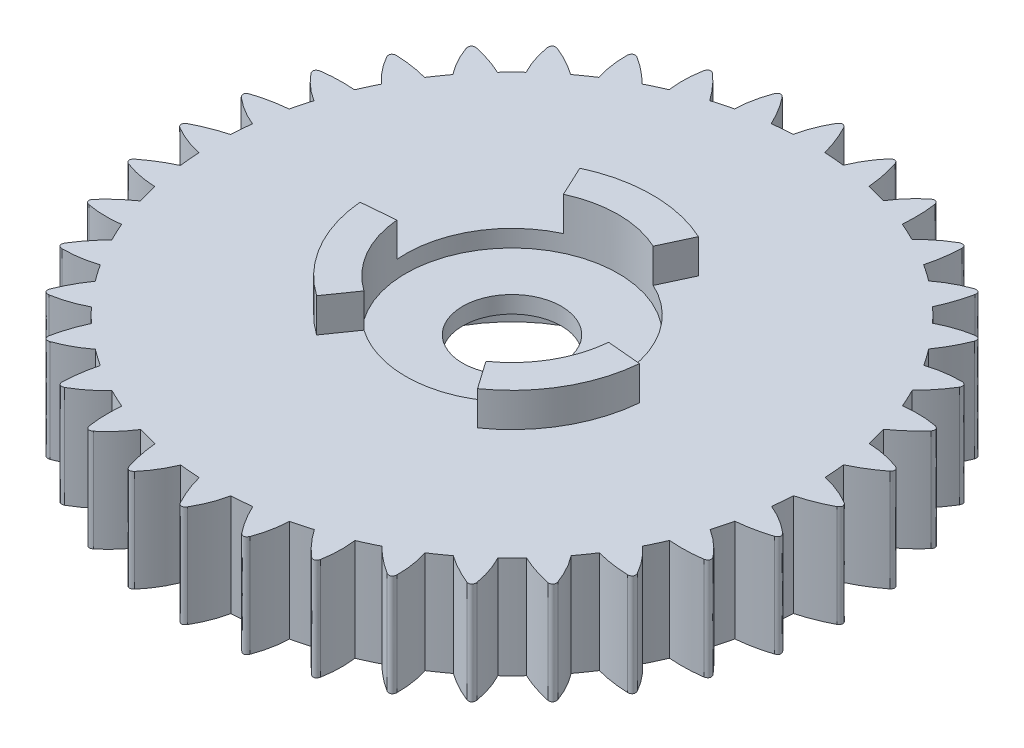
from build123d import *

# Parameters (mm, degrees)
SKETCH_1_R          = 17.5
EXTRUDE_1_DEPTH     = 6
SKETCH_2_R          = 8
CUT_EXTRUDE_1_DEPTH = 4
SKETCH_3_R          = 6.25
CUT_EXTRUDE_2_DEPTH = 1
SKETCH_4_R          = 2.9
CUT_EXTRUDE_3_DEPTH = 10
EXTRUDE_2_DEPTH     = 2
EXTRUDE_3_DEPTH     = 6


with BuildPart() as part:
    # 草图1 → 凸台-拉伸1 (new body)
    with BuildSketch(Plane(origin=(0, 0, 0), x_dir=(1, 0, 0), z_dir=(0, 1, 0))):
        Circle(SKETCH_1_R)
    extrude(amount=EXTRUDE_1_DEPTH)

    # 草图2 → 切除-拉伸1 (cut)
    with BuildSketch(Plane.XZ):
        Circle(SKETCH_2_R)
    extrude(amount=-CUT_EXTRUDE_1_DEPTH, mode=Mode.SUBTRACT)

    # 草图3 → 切除-拉伸2 (cut)
    with BuildSketch(Plane(origin=(0, 6, 0), x_dir=(1, 0, 0), z_dir=(0, 1, 0))):
        Circle(SKETCH_3_R)
    extrude(amount=-CUT_EXTRUDE_2_DEPTH, mode=Mode.SUBTRACT)

    # 草图4 → 切除-拉伸3 (cut)
    with BuildSketch(Plane.XZ.offset(-4)):
        Circle(SKETCH_4_R)
    extrude(amount=-CUT_EXTRUDE_3_DEPTH, mode=Mode.SUBTRACT)

    # 草图5 → 凸台-拉伸2 (add)
    with BuildSketch(Plane(origin=(0, 6, 0), x_dir=(1, 0, 0), z_dir=(0, 1, 0))):
        with BuildLine():
            Line((2.641364136, 5.664423669), (3.486600659, 7.477039243))
            ThreePointArc((3.486600659, 7.477039243), (0, 8.25), (-3.486600659, 7.477039243))
            Line((-3.486600659, 7.477039243), (-2.641364136, 5.664423669))
            ThreePointArc((-2.641364136, 5.664423669), (0, 6.25), (2.641364136, 5.664423669))
        make_face()
        with BuildLine():
            Line((3.584852727, -5.119700277), (4.7320056, -6.758004365))
            ThreePointArc((4.7320056, -6.758004365), (7.144709581, -4.125), (8.218606259, -0.719034878))
            Line((8.218606259, -0.719034878), (6.226216863, -0.544723392))
            ThreePointArc((6.226216863, -0.544723392), (5.412658774, -3.125), (3.584852727, -5.119700277))
        make_face()
        with BuildLine():
            Line((-6.226216863, -0.544723392), (-8.218606259, -0.719034878))
            ThreePointArc((-8.218606259, -0.719034878), (-7.144709581, -4.125), (-4.7320056, -6.758004365))
            Line((-4.7320056, -6.758004365), (-3.584852727, -5.119700277))
            ThreePointArc((-3.584852727, -5.119700277), (-5.412658774, -3.125), (-6.226216863, -0.544723392))
        make_face()
    extrude(amount=EXTRUDE_2_DEPTH)

    # 草图6 → 凸台-拉伸3 (add)
    with BuildSketch(Plane(origin=(0, 6, 0), x_dir=(1, 0, 0), z_dir=(0, 1, 0))):
        with BuildLine():
            Line((1.995624094, 17.076517128), (3.9652396, 16.729220773))
            add(Edge.make_bspline(
                [(3.546420744, 18.989060274), (3.785233358, 18.256333159), (3.924839643, 17.503053326), (3.9652396, 16.729220773)],
                knots=[0.14661217, 0.14661217, 0.14661217, 0.14661217, 1, 1, 1, 1], degree=3))
            add(Edge.make_bspline(
                [(3.137147772, 19.059965649), (3.395615745, 19.28991485), (3.546420744, 18.989060274)],
                knots=[0, 0, 0, 1, 1, 1], degree=2))
            add(Edge.make_bspline(
                [(3.137147772, 19.059965649), (2.636252172, 18.472842882), (2.255750312, 17.811700446), (1.995624094, 17.076517128)],
                knots=[0.150431817, 0.150431817, 0.150431817, 0.150431817, 1, 1, 1, 1], degree=3))
        make_face()
        with BuildLine():
            Line((-1, 17.163622949), (1, 17.163622949))
            add(Edge.make_bspline(
                [(0.195126932, 19.316403279), (0.557548174, 18.636277311), (0.825839196, 17.918683868), (1, 17.163622949)],
                knots=[0.14661217, 0.14661217, 0.14661217, 0.14661217, 1, 1, 1, 1], degree=3))
            add(Edge.make_bspline(
                [(-0.220240853, 19.315161937), (-0.005629849, 19.586500185), (0.195126932, 19.316403279)],
                knots=[0, 0, 0, 1, 1, 1], degree=2))
            add(Edge.make_bspline(
                [(-0.220240853, 19.315161937), (-0.611573925, 18.649979276), (-0.871488927, 17.932807625), (-1, 17.163622949)],
                knots=[0.150431817, 0.150431817, 0.150431817, 0.150431817, 1, 1, 1, 1], degree=3))
        make_face()
        with BuildLine():
            Line((4.93061216, 16.470549975), (6.809997402, 15.786509688))
            add(Edge.make_bspline(
                [(6.789958356, 18.08474428), (6.897906142, 17.321679562), (6.904585824, 16.555601365), (6.809997402, 15.786509688)],
                knots=[0.14661217, 0.14661217, 0.14661217, 0.14661217, 1, 1, 1, 1], degree=3))
            add(Edge.make_bspline(
                [(6.39921575, 18.225641949), (6.693687273, 18.407215213), (6.789958356, 18.08474428)],
                knots=[0, 0, 0, 1, 1, 1], degree=2))
            add(Edge.make_bspline(
                [(6.39921575, 18.225641949), (5.803977081, 17.734418505), (5.31444972, 17.149393763), (4.93061216, 16.470549975)],
                knots=[0.150431817, 0.150431817, 0.150431817, 0.150431817, 1, 1, 1, 1], degree=3))
        make_face()
        with BuildLine():
            Line((7.715786071, 15.364133495), (9.447836878, 14.364133495))
            add(Edge.make_bspline(
                [(9.82718652, 16.630932484), (9.800989538, 15.860715497), (9.674539658, 15.105115834), (9.447836878, 14.364133495)],
                knots=[0.14661217, 0.14661217, 0.14661217, 0.14661217, 1, 1, 1, 1], degree=3))
            add(Edge.make_bspline(
                [(9.466846795, 16.837541342), (9.7883745, 16.965221656), (9.82718652, 16.630932484)],
                knots=[0, 0, 0, 1, 1, 1], degree=2))
            add(Edge.make_bspline(
                [(9.466846795, 16.837541342), (8.795351083, 16.457142796), (8.211672262, 15.966011428), (7.715786071, 15.364133495)],
                knots=[0.150431817, 0.150431817, 0.150431817, 0.150431817, 1, 1, 1, 1], degree=3))
        make_face()
        with BuildLine():
            Line((10.266519726, 13.790885594), (11.798608612, 12.505310374))
            add(Edge.make_bspline(
                [(12.565820593, 14.671798219), (12.406274827, 13.917831617), (12.1505375, 13.195669002), (11.798608612, 12.505310374)],
                knots=[0.14661217, 0.14661217, 0.14661217, 0.14661217, 1, 1, 1, 1], degree=3))
            add(Edge.make_bspline(
                [(12.24683249, 14.937840561), (12.585646922, 15.007748424), (12.565820593, 14.671798219)],
                knots=[0, 0, 0, 1, 1, 1], degree=2))
            add(Edge.make_bspline(
                [(12.24683249, 14.937840561), (11.519482793, 14.67982513), (10.859387298, 14.297509915), (10.266519726, 13.790885594)],
                knots=[0.150431817, 0.150431817, 0.150431817, 0.150431817, 1, 1, 1, 1], degree=3))
        make_face()
        with BuildLine():
            Line((12.505310374, 11.798608612), (13.790885594, 10.266519726))
            add(Edge.make_bspline(
                [(14.922648567, 12.26686879), (14.634601733, 11.552061466), (14.257347408, 10.885278445), (13.790885594, 10.266519726)],
                knots=[0.14661217, 0.14661217, 0.14661217, 0.14661217, 1, 1, 1, 1], degree=3))
            add(Edge.make_bspline(
                [(14.654704378, 12.584261054), (15.00051083, 12.59427235), (14.922648567, 12.26686879)],
                knots=[0, 0, 0, 1, 1, 1], degree=2))
            add(Edge.make_bspline(
                [(14.654704378, 12.584261054), (13.893600847, 12.456468406), (13.177145346, 12.194585798), (12.505310374, 11.798608612)],
                knots=[0.150431817, 0.150431817, 0.150431817, 0.150431817, 1, 1, 1, 1], degree=3))
        make_face()
        with BuildLine():
            Line((14.364133495, 9.447836878), (15.364133495, 7.715786071))
            add(Edge.make_bspline(
                [(16.826059415, 9.48921676), (16.418263671, 8.835287773), (15.93095503, 8.24414421), (15.364133495, 7.715786071)],
                knots=[0.14661217, 0.14661217, 0.14661217, 0.14661217, 1, 1, 1, 1], degree=3))
            add(Edge.make_bspline(
                [(16.617300489, 9.848315142), (16.959591807, 9.798125685), (16.826059415, 9.48921676)],
                knots=[0, 0, 0, 1, 1, 1], degree=2))
            add(Edge.make_bspline(
                [(16.617300489, 9.848315142), (15.845568871, 9.854628193), (15.094522501, 9.721135363), (14.364133495, 9.447836878)],
                knots=[0.150431817, 0.150431817, 0.150431817, 0.150431817, 1, 1, 1, 1], degree=3))
        make_face()
        with BuildLine():
            Line((15.786509688, 6.809997402), (16.470549975, 4.93061216))
            add(Edge.make_bspline(
                [(18.218218963, 6.42323968), (17.703064975, 5.850058333), (17.120508645, 5.352515826), (16.470549975, 4.93061216)],
                knots=[0.14661217, 0.14661217, 0.14661217, 0.14661217, 1, 1, 1, 1], degree=3))
            add(Edge.make_bspline(
                [(18.074988333, 6.813133158), (18.403364169, 6.704267928), (18.218218963, 6.42323968)],
                knots=[0, 0, 0, 1, 1, 1], degree=2))
            add(Edge.make_bspline(
                [(18.074988333, 6.813133158), (17.316077302, 6.953360089), (16.553260227, 6.952313148), (15.786509688, 6.809997402)],
                knots=[0.150431817, 0.150431817, 0.150431817, 0.150431817, 1, 1, 1, 1], degree=3))
        make_face()
        with BuildLine():
            Line((16.729220773, 3.9652396), (17.076517128, 1.995624094))
            add(Edge.make_bspline(
                [(19.056827146, 3.162095713), (18.449967608, 2.687077829), (17.789864269, 2.298253956), (17.076517128, 1.995624094)],
                knots=[0.14661217, 0.14661217, 0.14661217, 0.14661217, 1, 1, 1, 1], degree=3))
            add(Edge.make_bspline(
                [(18.983476803, 3.570937571), (19.287959624, 3.406704383), (19.056827146, 3.162095713)],
                knots=[0, 0, 0, 1, 1, 1], degree=2))
            add(Edge.make_bspline(
                [(18.983476803, 3.570937571), (18.260445487, 3.840817658), (17.509035518, 3.972248417), (16.729220773, 3.9652396)],
                knots=[0.150431817, 0.150431817, 0.150431817, 0.150431817, 1, 1, 1, 1], degree=3))
        make_face()
        with BuildLine():
            Line((17.163622949, 1), (17.163622949, -1))
            add(Edge.make_bspline(
                [(19.316403279, -0.195126932), (18.636277311, -0.557548174), (17.918683868, -0.825839196), (17.163622949, -1)],
                knots=[0.14661217, 0.14661217, 0.14661217, 0.14661217, 1, 1, 1, 1], degree=3))
            add(Edge.make_bspline(
                [(19.315161937, 0.220240853), (19.586500185, 0.005629849), (19.316403279, -0.195126932)],
                knots=[0, 0, 0, 1, 1, 1], degree=2))
            add(Edge.make_bspline(
                [(19.315161937, 0.220240853), (18.649979276, 0.611573925), (17.932807625, 0.871488927), (17.163622949, 1)],
                knots=[0.150431817, 0.150431817, 0.150431817, 0.150431817, 1, 1, 1, 1], degree=3))
        make_face()
        with BuildLine():
            Line((17.076517128, -1.995624094), (16.729220773, -3.9652396))
            add(Edge.make_bspline(
                [(18.989060274, -3.546420744), (18.256333159, -3.785233358), (17.503053326, -3.924839643), (16.729220773, -3.9652396)],
                knots=[0.14661217, 0.14661217, 0.14661217, 0.14661217, 1, 1, 1, 1], degree=3))
            add(Edge.make_bspline(
                [(19.059965649, -3.137147772), (19.28991485, -3.395615745), (18.989060274, -3.546420744)],
                knots=[0, 0, 0, 1, 1, 1], degree=2))
            add(Edge.make_bspline(
                [(19.059965649, -3.137147772), (18.472842882, -2.636252172), (17.811700446, -2.255750312), (17.076517128, -1.995624094)],
                knots=[0.150431817, 0.150431817, 0.150431817, 0.150431817, 1, 1, 1, 1], degree=3))
        make_face()
        with BuildLine():
            Line((16.470549975, -4.93061216), (15.786509688, -6.809997402))
            add(Edge.make_bspline(
                [(18.08474428, -6.789958356), (17.321679562, -6.897906142), (16.555601365, -6.904585824), (15.786509688, -6.809997402)],
                knots=[0.14661217, 0.14661217, 0.14661217, 0.14661217, 1, 1, 1, 1], degree=3))
            add(Edge.make_bspline(
                [(18.225641949, -6.39921575), (18.407215213, -6.693687273), (18.08474428, -6.789958356)],
                knots=[0, 0, 0, 1, 1, 1], degree=2))
            add(Edge.make_bspline(
                [(18.225641949, -6.39921575), (17.734418505, -5.803977081), (17.149393763, -5.31444972), (16.470549975, -4.93061216)],
                knots=[0.150431817, 0.150431817, 0.150431817, 0.150431817, 1, 1, 1, 1], degree=3))
        make_face()
        with BuildLine():
            Line((15.364133495, -7.715786071), (14.364133495, -9.447836878))
            add(Edge.make_bspline(
                [(16.630932484, -9.82718652), (15.860715497, -9.800989538), (15.105115834, -9.674539658), (14.364133495, -9.447836878)],
                knots=[0.14661217, 0.14661217, 0.14661217, 0.14661217, 1, 1, 1, 1], degree=3))
            add(Edge.make_bspline(
                [(16.837541342, -9.466846795), (16.965221656, -9.7883745), (16.630932484, -9.82718652)],
                knots=[0, 0, 0, 1, 1, 1], degree=2))
            add(Edge.make_bspline(
                [(16.837541342, -9.466846795), (16.457142796, -8.795351083), (15.966011428, -8.211672262), (15.364133495, -7.715786071)],
                knots=[0.150431817, 0.150431817, 0.150431817, 0.150431817, 1, 1, 1, 1], degree=3))
        make_face()
        with BuildLine():
            Line((13.790885594, -10.266519726), (12.505310374, -11.798608612))
            add(Edge.make_bspline(
                [(14.671798219, -12.565820593), (13.917831617, -12.406274827), (13.195669002, -12.1505375), (12.505310374, -11.798608612)],
                knots=[0.14661217, 0.14661217, 0.14661217, 0.14661217, 1, 1, 1, 1], degree=3))
            add(Edge.make_bspline(
                [(14.937840561, -12.24683249), (15.007748424, -12.585646922), (14.671798219, -12.565820593)],
                knots=[0, 0, 0, 1, 1, 1], degree=2))
            add(Edge.make_bspline(
                [(14.937840561, -12.24683249), (14.67982513, -11.519482793), (14.297509915, -10.859387298), (13.790885594, -10.266519726)],
                knots=[0.150431817, 0.150431817, 0.150431817, 0.150431817, 1, 1, 1, 1], degree=3))
        make_face()
        with BuildLine():
            Line((11.798608612, -12.505310374), (10.266519726, -13.790885594))
            add(Edge.make_bspline(
                [(12.26686879, -14.922648567), (11.552061466, -14.634601733), (10.885278445, -14.257347408), (10.266519726, -13.790885594)],
                knots=[0.14661217, 0.14661217, 0.14661217, 0.14661217, 1, 1, 1, 1], degree=3))
            add(Edge.make_bspline(
                [(12.584261054, -14.654704378), (12.59427235, -15.00051083), (12.26686879, -14.922648567)],
                knots=[0, 0, 0, 1, 1, 1], degree=2))
            add(Edge.make_bspline(
                [(12.584261054, -14.654704378), (12.456468406, -13.893600847), (12.194585798, -13.177145346), (11.798608612, -12.505310374)],
                knots=[0.150431817, 0.150431817, 0.150431817, 0.150431817, 1, 1, 1, 1], degree=3))
        make_face()
        with BuildLine():
            Line((9.447836878, -14.364133495), (7.715786071, -15.364133495))
            add(Edge.make_bspline(
                [(9.48921676, -16.826059415), (8.835287773, -16.418263671), (8.24414421, -15.93095503), (7.715786071, -15.364133495)],
                knots=[0.14661217, 0.14661217, 0.14661217, 0.14661217, 1, 1, 1, 1], degree=3))
            add(Edge.make_bspline(
                [(9.848315142, -16.617300489), (9.798125685, -16.959591807), (9.48921676, -16.826059415)],
                knots=[0, 0, 0, 1, 1, 1], degree=2))
            add(Edge.make_bspline(
                [(9.848315142, -16.617300489), (9.854628193, -15.845568871), (9.721135363, -15.094522501), (9.447836878, -14.364133495)],
                knots=[0.150431817, 0.150431817, 0.150431817, 0.150431817, 1, 1, 1, 1], degree=3))
        make_face()
        with BuildLine():
            Line((6.809997402, -15.786509688), (4.93061216, -16.470549975))
            add(Edge.make_bspline(
                [(6.42323968, -18.218218963), (5.850058333, -17.703064975), (5.352515826, -17.120508645), (4.93061216, -16.470549975)],
                knots=[0.14661217, 0.14661217, 0.14661217, 0.14661217, 1, 1, 1, 1], degree=3))
            add(Edge.make_bspline(
                [(6.813133158, -18.074988333), (6.704267928, -18.403364169), (6.42323968, -18.218218963)],
                knots=[0, 0, 0, 1, 1, 1], degree=2))
            add(Edge.make_bspline(
                [(6.813133158, -18.074988333), (6.953360089, -17.316077302), (6.952313148, -16.553260227), (6.809997402, -15.786509688)],
                knots=[0.150431817, 0.150431817, 0.150431817, 0.150431817, 1, 1, 1, 1], degree=3))
        make_face()
        with BuildLine():
            Line((3.9652396, -16.729220772), (1.995624094, -17.076517128))
            add(Edge.make_bspline(
                [(3.162095713, -19.056827146), (2.687077829, -18.449967608), (2.298253956, -17.789864269), (1.995624094, -17.076517128)],
                knots=[0.14661217, 0.14661217, 0.14661217, 0.14661217, 1, 1, 1, 1], degree=3))
            add(Edge.make_bspline(
                [(3.570937571, -18.983476803), (3.406704383, -19.287959624), (3.162095713, -19.056827146)],
                knots=[0, 0, 0, 1, 1, 1], degree=2))
            add(Edge.make_bspline(
                [(3.570937571, -18.983476803), (3.840817658, -18.260445487), (3.972248417, -17.509035518), (3.9652396, -16.729220772)],
                knots=[0.150431817, 0.150431817, 0.150431817, 0.150431817, 1, 1, 1, 1], degree=3))
        make_face()
        with BuildLine():
            Line((1, -17.163622949), (-1, -17.163622949))
            add(Edge.make_bspline(
                [(-0.195126932, -19.316403279), (-0.557548174, -18.636277311), (-0.825839196, -17.918683868), (-1, -17.163622949)],
                knots=[0.14661217, 0.14661217, 0.14661217, 0.14661217, 1, 1, 1, 1], degree=3))
            add(Edge.make_bspline(
                [(0.220240853, -19.315161937), (0.005629849, -19.586500185), (-0.195126932, -19.316403279)],
                knots=[0, 0, 0, 1, 1, 1], degree=2))
            add(Edge.make_bspline(
                [(0.220240853, -19.315161937), (0.611573925, -18.649979276), (0.871488927, -17.932807625), (1, -17.163622949)],
                knots=[0.150431817, 0.150431817, 0.150431817, 0.150431817, 1, 1, 1, 1], degree=3))
        make_face()
        with BuildLine():
            Line((-1.995624094, -17.076517128), (-3.9652396, -16.729220772))
            add(Edge.make_bspline(
                [(-3.546420744, -18.989060274), (-3.785233358, -18.256333159), (-3.924839643, -17.503053326), (-3.9652396, -16.729220772)],
                knots=[0.14661217, 0.14661217, 0.14661217, 0.14661217, 1, 1, 1, 1], degree=3))
            add(Edge.make_bspline(
                [(-3.137147772, -19.059965649), (-3.395615745, -19.28991485), (-3.546420744, -18.989060274)],
                knots=[0, 0, 0, 1, 1, 1], degree=2))
            add(Edge.make_bspline(
                [(-3.137147772, -19.059965649), (-2.636252172, -18.472842882), (-2.255750312, -17.811700446), (-1.995624094, -17.076517128)],
                knots=[0.150431817, 0.150431817, 0.150431817, 0.150431817, 1, 1, 1, 1], degree=3))
        make_face()
        with BuildLine():
            Line((-4.93061216, -16.470549975), (-6.809997402, -15.786509688))
            add(Edge.make_bspline(
                [(-6.789958356, -18.08474428), (-6.897906142, -17.321679562), (-6.904585824, -16.555601365), (-6.809997402, -15.786509688)],
                knots=[0.14661217, 0.14661217, 0.14661217, 0.14661217, 1, 1, 1, 1], degree=3))
            add(Edge.make_bspline(
                [(-6.39921575, -18.225641949), (-6.693687273, -18.407215213), (-6.789958356, -18.08474428)],
                knots=[0, 0, 0, 1, 1, 1], degree=2))
            add(Edge.make_bspline(
                [(-6.39921575, -18.225641949), (-5.803977081, -17.734418505), (-5.31444972, -17.149393763), (-4.93061216, -16.470549975)],
                knots=[0.150431817, 0.150431817, 0.150431817, 0.150431817, 1, 1, 1, 1], degree=3))
        make_face()
        with BuildLine():
            Line((-7.715786071, -15.364133495), (-9.447836878, -14.364133495))
            add(Edge.make_bspline(
                [(-9.82718652, -16.630932484), (-9.800989538, -15.860715497), (-9.674539658, -15.105115834), (-9.447836878, -14.364133495)],
                knots=[0.14661217, 0.14661217, 0.14661217, 0.14661217, 1, 1, 1, 1], degree=3))
            add(Edge.make_bspline(
                [(-9.466846795, -16.837541342), (-9.7883745, -16.965221656), (-9.82718652, -16.630932484)],
                knots=[0, 0, 0, 1, 1, 1], degree=2))
            add(Edge.make_bspline(
                [(-9.466846795, -16.837541342), (-8.795351083, -16.457142796), (-8.211672262, -15.966011428), (-7.715786071, -15.364133495)],
                knots=[0.150431817, 0.150431817, 0.150431817, 0.150431817, 1, 1, 1, 1], degree=3))
        make_face()
        with BuildLine():
            Line((-10.266519726, -13.790885594), (-11.798608612, -12.505310374))
            add(Edge.make_bspline(
                [(-12.565820593, -14.671798219), (-12.406274827, -13.917831617), (-12.1505375, -13.195669002), (-11.798608612, -12.505310374)],
                knots=[0.14661217, 0.14661217, 0.14661217, 0.14661217, 1, 1, 1, 1], degree=3))
            add(Edge.make_bspline(
                [(-12.24683249, -14.937840561), (-12.585646922, -15.007748424), (-12.565820593, -14.671798219)],
                knots=[0, 0, 0, 1, 1, 1], degree=2))
            add(Edge.make_bspline(
                [(-12.24683249, -14.937840561), (-11.519482793, -14.67982513), (-10.859387298, -14.297509915), (-10.266519726, -13.790885594)],
                knots=[0.150431817, 0.150431817, 0.150431817, 0.150431817, 1, 1, 1, 1], degree=3))
        make_face()
        with BuildLine():
            Line((-12.505310374, -11.798608612), (-13.790885594, -10.266519726))
            add(Edge.make_bspline(
                [(-14.922648567, -12.26686879), (-14.634601733, -11.552061466), (-14.257347408, -10.885278445), (-13.790885594, -10.266519726)],
                knots=[0.14661217, 0.14661217, 0.14661217, 0.14661217, 1, 1, 1, 1], degree=3))
            add(Edge.make_bspline(
                [(-14.654704378, -12.584261054), (-15.00051083, -12.59427235), (-14.922648567, -12.26686879)],
                knots=[0, 0, 0, 1, 1, 1], degree=2))
            add(Edge.make_bspline(
                [(-14.654704378, -12.584261054), (-13.893600847, -12.456468406), (-13.177145346, -12.194585798), (-12.505310374, -11.798608612)],
                knots=[0.150431817, 0.150431817, 0.150431817, 0.150431817, 1, 1, 1, 1], degree=3))
        make_face()
        with BuildLine():
            Line((-14.364133495, -9.447836878), (-15.364133495, -7.715786071))
            add(Edge.make_bspline(
                [(-16.826059415, -9.48921676), (-16.418263671, -8.835287773), (-15.93095503, -8.24414421), (-15.364133495, -7.715786071)],
                knots=[0.14661217, 0.14661217, 0.14661217, 0.14661217, 1, 1, 1, 1], degree=3))
            add(Edge.make_bspline(
                [(-16.617300489, -9.848315142), (-16.959591807, -9.798125685), (-16.826059415, -9.48921676)],
                knots=[0, 0, 0, 1, 1, 1], degree=2))
            add(Edge.make_bspline(
                [(-16.617300489, -9.848315142), (-15.845568871, -9.854628193), (-15.094522501, -9.721135363), (-14.364133495, -9.447836878)],
                knots=[0.150431817, 0.150431817, 0.150431817, 0.150431817, 1, 1, 1, 1], degree=3))
        make_face()
        with BuildLine():
            Line((-15.786509688, -6.809997402), (-16.470549975, -4.93061216))
            add(Edge.make_bspline(
                [(-18.218218963, -6.42323968), (-17.703064975, -5.850058333), (-17.120508645, -5.352515826), (-16.470549975, -4.93061216)],
                knots=[0.14661217, 0.14661217, 0.14661217, 0.14661217, 1, 1, 1, 1], degree=3))
            add(Edge.make_bspline(
                [(-18.074988333, -6.813133158), (-18.403364169, -6.704267928), (-18.218218963, -6.42323968)],
                knots=[0, 0, 0, 1, 1, 1], degree=2))
            add(Edge.make_bspline(
                [(-18.074988333, -6.813133158), (-17.316077302, -6.953360089), (-16.553260227, -6.952313148), (-15.786509688, -6.809997402)],
                knots=[0.150431817, 0.150431817, 0.150431817, 0.150431817, 1, 1, 1, 1], degree=3))
        make_face()
        with BuildLine():
            Line((-16.729220772, -3.9652396), (-17.076517128, -1.995624094))
            add(Edge.make_bspline(
                [(-19.056827146, -3.162095713), (-18.449967608, -2.687077829), (-17.789864269, -2.298253956), (-17.076517128, -1.995624094)],
                knots=[0.14661217, 0.14661217, 0.14661217, 0.14661217, 1, 1, 1, 1], degree=3))
            add(Edge.make_bspline(
                [(-18.983476803, -3.570937571), (-19.287959624, -3.406704383), (-19.056827146, -3.162095713)],
                knots=[0, 0, 0, 1, 1, 1], degree=2))
            add(Edge.make_bspline(
                [(-18.983476803, -3.570937571), (-18.260445487, -3.840817658), (-17.509035518, -3.972248417), (-16.729220772, -3.9652396)],
                knots=[0.150431817, 0.150431817, 0.150431817, 0.150431817, 1, 1, 1, 1], degree=3))
        make_face()
        with BuildLine():
            Line((-17.163622949, -1), (-17.163622949, 1))
            add(Edge.make_bspline(
                [(-19.316403279, 0.195126932), (-18.636277311, 0.557548174), (-17.918683868, 0.825839196), (-17.163622949, 1)],
                knots=[0.14661217, 0.14661217, 0.14661217, 0.14661217, 1, 1, 1, 1], degree=3))
            add(Edge.make_bspline(
                [(-19.315161937, -0.220240853), (-19.586500185, -0.005629849), (-19.316403279, 0.195126932)],
                knots=[0, 0, 0, 1, 1, 1], degree=2))
            add(Edge.make_bspline(
                [(-19.315161937, -0.220240853), (-18.649979276, -0.611573925), (-17.932807625, -0.871488927), (-17.163622949, -1)],
                knots=[0.150431817, 0.150431817, 0.150431817, 0.150431817, 1, 1, 1, 1], degree=3))
        make_face()
        with BuildLine():
            Line((-17.076517128, 1.995624094), (-16.729220772, 3.9652396))
            add(Edge.make_bspline(
                [(-18.989060274, 3.546420744), (-18.256333159, 3.785233358), (-17.503053326, 3.924839643), (-16.729220772, 3.9652396)],
                knots=[0.14661217, 0.14661217, 0.14661217, 0.14661217, 1, 1, 1, 1], degree=3))
            add(Edge.make_bspline(
                [(-19.059965649, 3.137147772), (-19.28991485, 3.395615745), (-18.989060274, 3.546420744)],
                knots=[0, 0, 0, 1, 1, 1], degree=2))
            add(Edge.make_bspline(
                [(-19.059965649, 3.137147772), (-18.472842882, 2.636252172), (-17.811700446, 2.255750312), (-17.076517128, 1.995624094)],
                knots=[0.150431817, 0.150431817, 0.150431817, 0.150431817, 1, 1, 1, 1], degree=3))
        make_face()
        with BuildLine():
            Line((-16.470549975, 4.93061216), (-15.786509688, 6.809997402))
            add(Edge.make_bspline(
                [(-18.08474428, 6.789958356), (-17.321679562, 6.897906142), (-16.555601365, 6.904585824), (-15.786509688, 6.809997402)],
                knots=[0.14661217, 0.14661217, 0.14661217, 0.14661217, 1, 1, 1, 1], degree=3))
            add(Edge.make_bspline(
                [(-18.225641949, 6.39921575), (-18.407215213, 6.693687273), (-18.08474428, 6.789958356)],
                knots=[0, 0, 0, 1, 1, 1], degree=2))
            add(Edge.make_bspline(
                [(-18.225641949, 6.39921575), (-17.734418505, 5.803977081), (-17.149393763, 5.31444972), (-16.470549975, 4.93061216)],
                knots=[0.150431817, 0.150431817, 0.150431817, 0.150431817, 1, 1, 1, 1], degree=3))
        make_face()
        with BuildLine():
            Line((-15.364133495, 7.715786071), (-14.364133495, 9.447836878))
            add(Edge.make_bspline(
                [(-16.630932484, 9.82718652), (-15.860715497, 9.800989538), (-15.105115834, 9.674539658), (-14.364133495, 9.447836878)],
                knots=[0.14661217, 0.14661217, 0.14661217, 0.14661217, 1, 1, 1, 1], degree=3))
            add(Edge.make_bspline(
                [(-16.837541342, 9.466846795), (-16.965221656, 9.7883745), (-16.630932484, 9.82718652)],
                knots=[0, 0, 0, 1, 1, 1], degree=2))
            add(Edge.make_bspline(
                [(-16.837541342, 9.466846795), (-16.457142796, 8.795351083), (-15.966011428, 8.211672262), (-15.364133495, 7.715786071)],
                knots=[0.150431817, 0.150431817, 0.150431817, 0.150431817, 1, 1, 1, 1], degree=3))
        make_face()
        with BuildLine():
            Line((-13.790885594, 10.266519726), (-12.505310374, 11.798608612))
            add(Edge.make_bspline(
                [(-14.671798219, 12.565820593), (-13.917831617, 12.406274827), (-13.195669002, 12.1505375), (-12.505310374, 11.798608612)],
                knots=[0.14661217, 0.14661217, 0.14661217, 0.14661217, 1, 1, 1, 1], degree=3))
            add(Edge.make_bspline(
                [(-14.937840561, 12.24683249), (-15.007748424, 12.585646922), (-14.671798219, 12.565820593)],
                knots=[0, 0, 0, 1, 1, 1], degree=2))
            add(Edge.make_bspline(
                [(-14.937840561, 12.24683249), (-14.67982513, 11.519482793), (-14.297509915, 10.859387298), (-13.790885594, 10.266519726)],
                knots=[0.150431817, 0.150431817, 0.150431817, 0.150431817, 1, 1, 1, 1], degree=3))
        make_face()
        with BuildLine():
            Line((-11.798608612, 12.505310374), (-10.266519726, 13.790885594))
            add(Edge.make_bspline(
                [(-12.26686879, 14.922648567), (-11.552061466, 14.634601733), (-10.885278445, 14.257347408), (-10.266519726, 13.790885594)],
                knots=[0.14661217, 0.14661217, 0.14661217, 0.14661217, 1, 1, 1, 1], degree=3))
            add(Edge.make_bspline(
                [(-12.584261054, 14.654704378), (-12.59427235, 15.00051083), (-12.26686879, 14.922648567)],
                knots=[0, 0, 0, 1, 1, 1], degree=2))
            add(Edge.make_bspline(
                [(-12.584261054, 14.654704378), (-12.456468406, 13.893600847), (-12.194585798, 13.177145346), (-11.798608612, 12.505310374)],
                knots=[0.150431817, 0.150431817, 0.150431817, 0.150431817, 1, 1, 1, 1], degree=3))
        make_face()
        with BuildLine():
            Line((-9.447836878, 14.364133495), (-7.715786071, 15.364133495))
            add(Edge.make_bspline(
                [(-9.48921676, 16.826059415), (-8.835287773, 16.418263671), (-8.24414421, 15.93095503), (-7.715786071, 15.364133495)],
                knots=[0.14661217, 0.14661217, 0.14661217, 0.14661217, 1, 1, 1, 1], degree=3))
            add(Edge.make_bspline(
                [(-9.848315142, 16.617300489), (-9.798125685, 16.959591807), (-9.48921676, 16.826059415)],
                knots=[0, 0, 0, 1, 1, 1], degree=2))
            add(Edge.make_bspline(
                [(-9.848315142, 16.617300489), (-9.854628193, 15.845568871), (-9.721135363, 15.094522501), (-9.447836878, 14.364133495)],
                knots=[0.150431817, 0.150431817, 0.150431817, 0.150431817, 1, 1, 1, 1], degree=3))
        make_face()
        with BuildLine():
            Line((-6.809997402, 15.786509688), (-4.93061216, 16.470549975))
            add(Edge.make_bspline(
                [(-6.42323968, 18.218218963), (-5.850058333, 17.703064975), (-5.352515826, 17.120508645), (-4.93061216, 16.470549975)],
                knots=[0.14661217, 0.14661217, 0.14661217, 0.14661217, 1, 1, 1, 1], degree=3))
            add(Edge.make_bspline(
                [(-6.813133158, 18.074988333), (-6.704267928, 18.403364169), (-6.42323968, 18.218218963)],
                knots=[0, 0, 0, 1, 1, 1], degree=2))
            add(Edge.make_bspline(
                [(-6.813133158, 18.074988333), (-6.953360089, 17.316077302), (-6.952313148, 16.553260227), (-6.809997402, 15.786509688)],
                knots=[0.150431817, 0.150431817, 0.150431817, 0.150431817, 1, 1, 1, 1], degree=3))
        make_face()
        with BuildLine():
            Line((-3.9652396, 16.729220772), (-1.995624094, 17.076517128))
            add(Edge.make_bspline(
                [(-3.162095713, 19.056827146), (-2.687077829, 18.449967608), (-2.298253956, 17.789864269), (-1.995624094, 17.076517128)],
                knots=[0.14661217, 0.14661217, 0.14661217, 0.14661217, 1, 1, 1, 1], degree=3))
            add(Edge.make_bspline(
                [(-3.570937571, 18.983476803), (-3.406704383, 19.287959624), (-3.162095713, 19.056827146)],
                knots=[0, 0, 0, 1, 1, 1], degree=2))
            add(Edge.make_bspline(
                [(-3.570937571, 18.983476803), (-3.840817658, 18.260445487), (-3.972248417, 17.509035518), (-3.9652396, 16.729220772)],
                knots=[0.150431817, 0.150431817, 0.150431817, 0.150431817, 1, 1, 1, 1], degree=3))
        make_face()
    extrude(amount=-EXTRUDE_3_DEPTH)


solid = part.part
